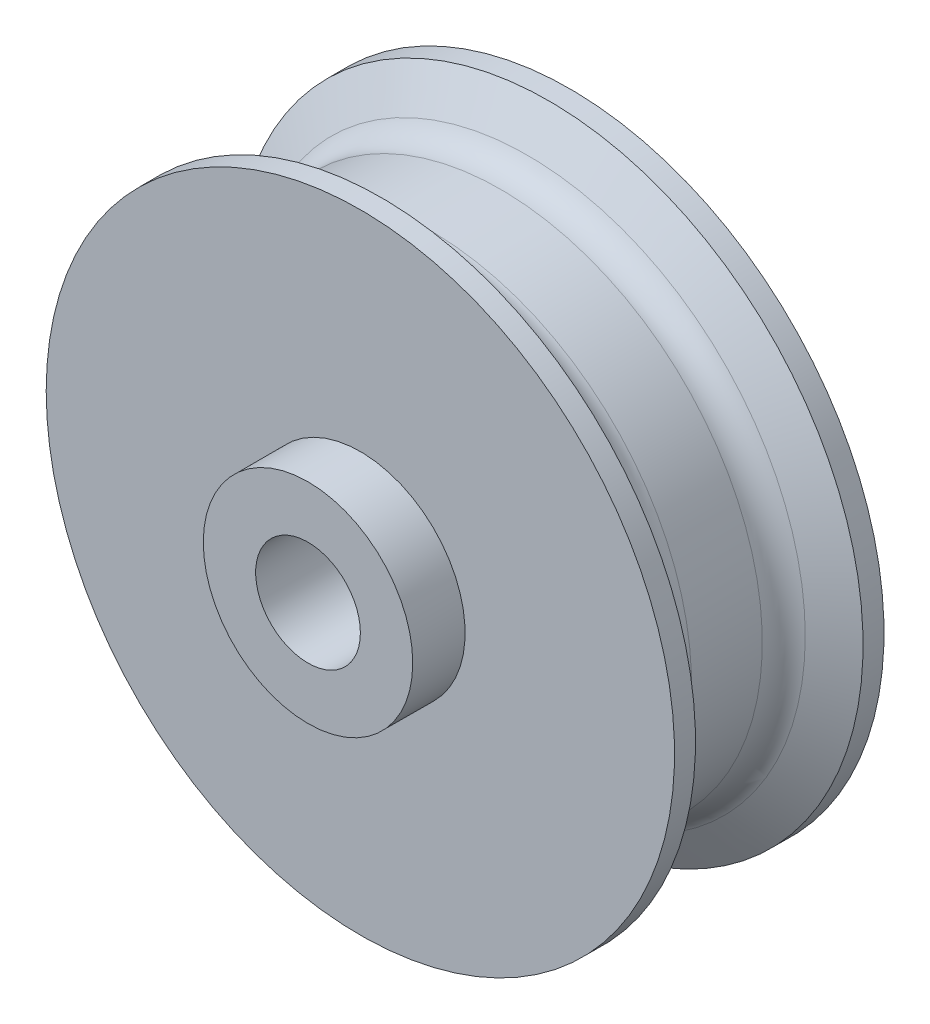
from build123d import *

# Parameters (mm, degrees)
SKETCH1_R           = 10
SKETCH1_R_2         = 5
BOSS_EXTRUDE1_DEPTH = 30
FILLET1_R           = 3


with BuildPart() as part:
    # Sketch1 → Boss-Extrude1 (new body)
    with BuildSketch(Plane.XY):
        Circle(SKETCH1_R)
        Circle(SKETCH1_R_2, mode=Mode.SUBTRACT)
    extrude(amount=BOSS_EXTRUDE1_DEPTH)

    # Sketch4 → Revolve1 (revolve)
    with BuildSketch(Plane(origin=(0, 0, 0), x_dir=(1, 0, 0), z_dir=(0, 1, 0))):
        Polygon((10, -5), (30, -5), (30, -7), (25, -9.886751346), (25, -20.113248654), (30, -23), (30, -25), (10, -25), align=None)
    revolve(axis=Axis((0, 0, 0), (0, 0, 1)))

    # Fillet1
    fillet1_edges = [part.edges().sort_by_distance(p)[0] for p in [
        (-25, 0, 20.113248654),
        (-25, 0, 9.886751346),
    ]]
    fillet(fillet1_edges, radius=FILLET1_R)


solid = part.part
